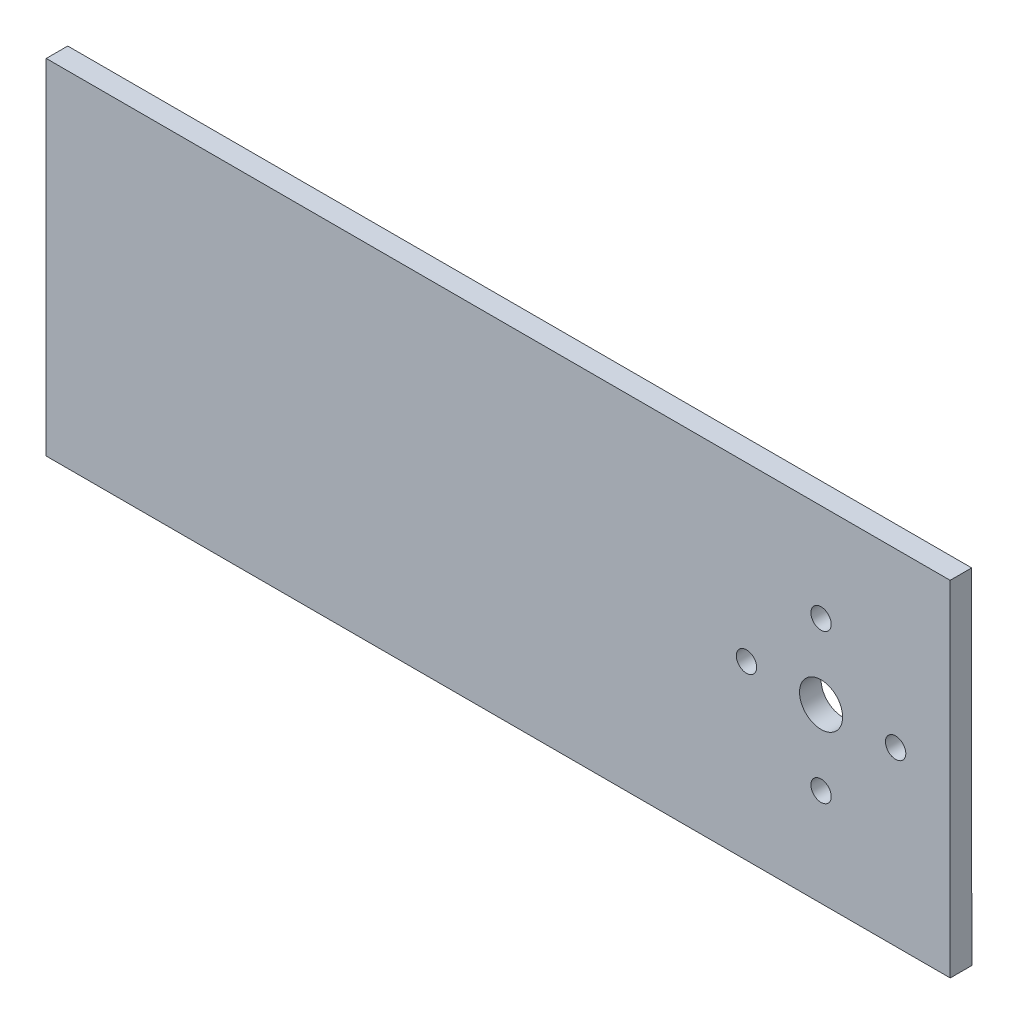
from build123d import *

# Parameters (mm, degrees)
SKETCH1_R           = 3.175
SKETCH1_R_2         = 1.5
BOSS_EXTRUDE1_DEPTH = 3.175


with BuildPart() as part:
    # Sketch1 → Boss-Extrude1 (new body)
    with BuildSketch(Plane.XY.offset(50.8)):
        Polygon((0, 25.4), (-12.7, 25.4), (-12.7, -25.4), (0, -25.4), (120.657586649, -25.4), (120.64241505, 25.4), align=None)
        with Locations((101.6, 0)):
            Circle(SKETCH1_R, mode=Mode.SUBTRACT)
        with Locations((101.6, 11)):
            Circle(SKETCH1_R_2, mode=Mode.SUBTRACT)
        with Locations((112.6, 0)):
            Circle(SKETCH1_R_2, mode=Mode.SUBTRACT)
        with Locations((101.6, -11)):
            Circle(SKETCH1_R_2, mode=Mode.SUBTRACT)
        with Locations((90.6, 0)):
            Circle(SKETCH1_R_2, mode=Mode.SUBTRACT)
    extrude(amount=BOSS_EXTRUDE1_DEPTH)


solid = part.part
